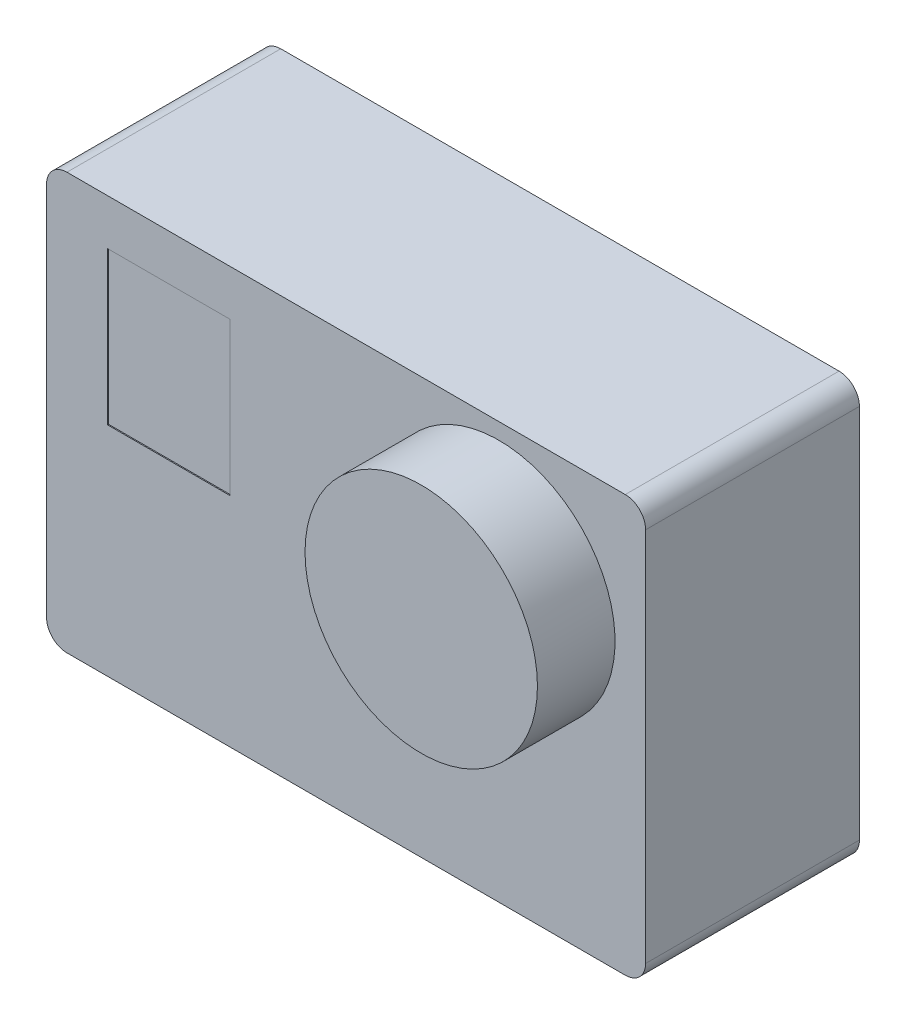
from build123d import *

# Parameters (mm, degrees)
SKETCH1_W           = 58.84
SKETCH1_H           = 40.89
BOSS_EXTRUDE1_DEPTH = 10.5
SKETCH2_R           = 11.415
BOSS_EXTRUDE2_DEPTH = 7.62
SKETCH4_W           = 12
SKETCH4_H           = 15
CUT_EXTRUDE1_DEPTH  = 0.1
FILLET1_R           = 2


with BuildPart() as part:
    # Sketch1 → Boss-Extrude1 (new body, symmetric)
    with BuildSketch(Plane.XY):
        Rectangle(SKETCH1_W, SKETCH1_H)
    extrude(amount=BOSS_EXTRUDE1_DEPTH, both=True)

    # Sketch2 → Boss-Extrude2 (add)
    with BuildSketch(Plane.XY.offset(10.5)):
        with Locations((15, 7.445)):
            Circle(SKETCH2_R)
    extrude(amount=BOSS_EXTRUDE2_DEPTH)

    # Sketch4 → Cut-Extrude1 (cut)
    with BuildSketch(Plane.XY.offset(10.5)):
        with Locations((-17.42, 8.445)):
            Rectangle(SKETCH4_W, SKETCH4_H)
    extrude(amount=-CUT_EXTRUDE1_DEPTH, mode=Mode.SUBTRACT)

    # Fillet1
    fillet1_edges = [part.edges().sort_by_distance(p)[0] for p in [
        (29.42, -20.445, 0),
        (-29.42, -20.445, 0),
        (-29.42, 20.445, 0),
        (29.42, 20.445, 0),
    ]]
    fillet(fillet1_edges, radius=FILLET1_R)


solid = part.part
